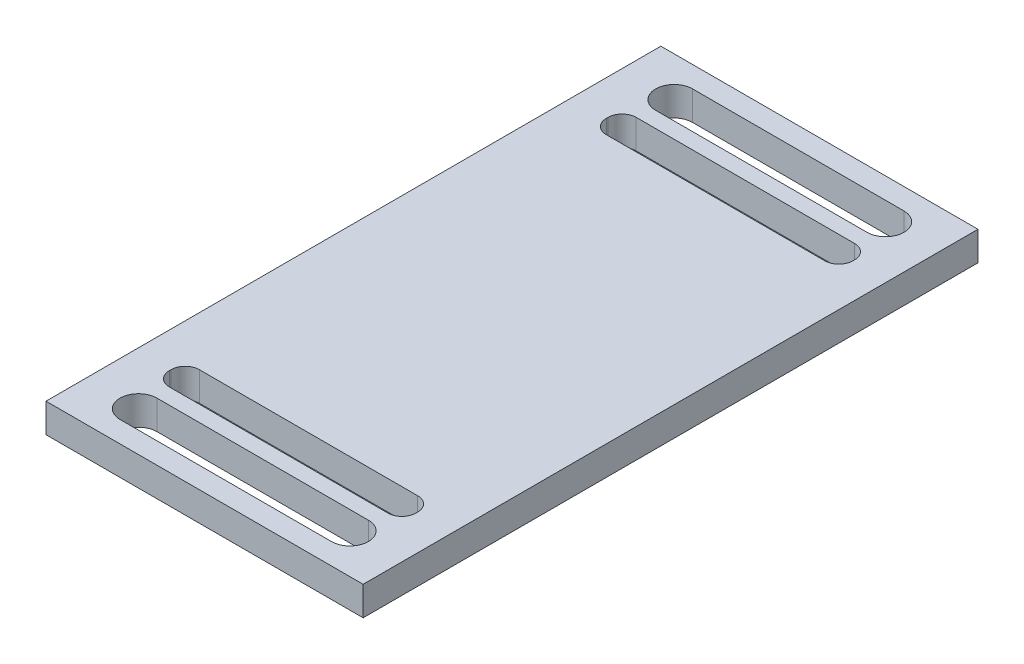
from build123d import *

# Parameters (mm, degrees)
SKIZZE1_W                       = 18
SKIZZE1_H                       = 34.9
SKIZZE1_W_2                     = 14
SKIZZE1_H_2                     = 1.7
AUFSATZ_LINEAR_AUSTRAGEN1_DEPTH = 0.825
VERRUNDUNG1_R                   = 0.8


with BuildPart() as part:
    # Skizze1 → Aufsatz-Linear austragen1 (new body, symmetric)
    with BuildSketch(Plane(origin=(0, 0, 0), x_dir=(1, 0, 0), z_dir=(0, 1, 0))):
        Rectangle(SKIZZE1_W, SKIZZE1_H)
        with Locations((0, 12.4)):
            Rectangle(SKIZZE1_W_2, SKIZZE1_H_2, mode=Mode.SUBTRACT)
        with BuildLine():
            Line((-6, 16.25), (6, 16.25))
            ThreePointArc((6, 16.25), (7.05, 15.2), (6, 14.15))
            Line((6, 14.15), (-6, 14.15))
            ThreePointArc((-6, 14.15), (-7.05, 15.2), (-6, 16.25))
        make_face(mode=Mode.SUBTRACT)
        with BuildLine():
            Line((-6, -16.25), (6, -16.25))
            ThreePointArc((6, -16.25), (7.05, -15.2), (6, -14.15))
            Line((6, -14.15), (-6, -14.15))
            ThreePointArc((-6, -14.15), (-7.05, -15.2), (-6, -16.25))
        make_face(mode=Mode.SUBTRACT)
        with Locations((0, -12.4)):
            Rectangle(SKIZZE1_W_2, SKIZZE1_H_2, mode=Mode.SUBTRACT)
    extrude(amount=AUFSATZ_LINEAR_AUSTRAGEN1_DEPTH, both=True)

    # Verrundung1
    verrundung1_edges = [part.edges().sort_by_distance(p)[0] for p in [
        (-7, 0, -11.55),
        (-7, 0, -13.25),
        (7, 0, -13.25),
        (7, 0, -11.55),
        (7, 0, 13.25),
        (-7, 0, 13.25),
        (-7, 0, 11.55),
        (7, 0, 11.55),
    ]]
    fillet(verrundung1_edges, radius=VERRUNDUNG1_R)


solid = part.part
